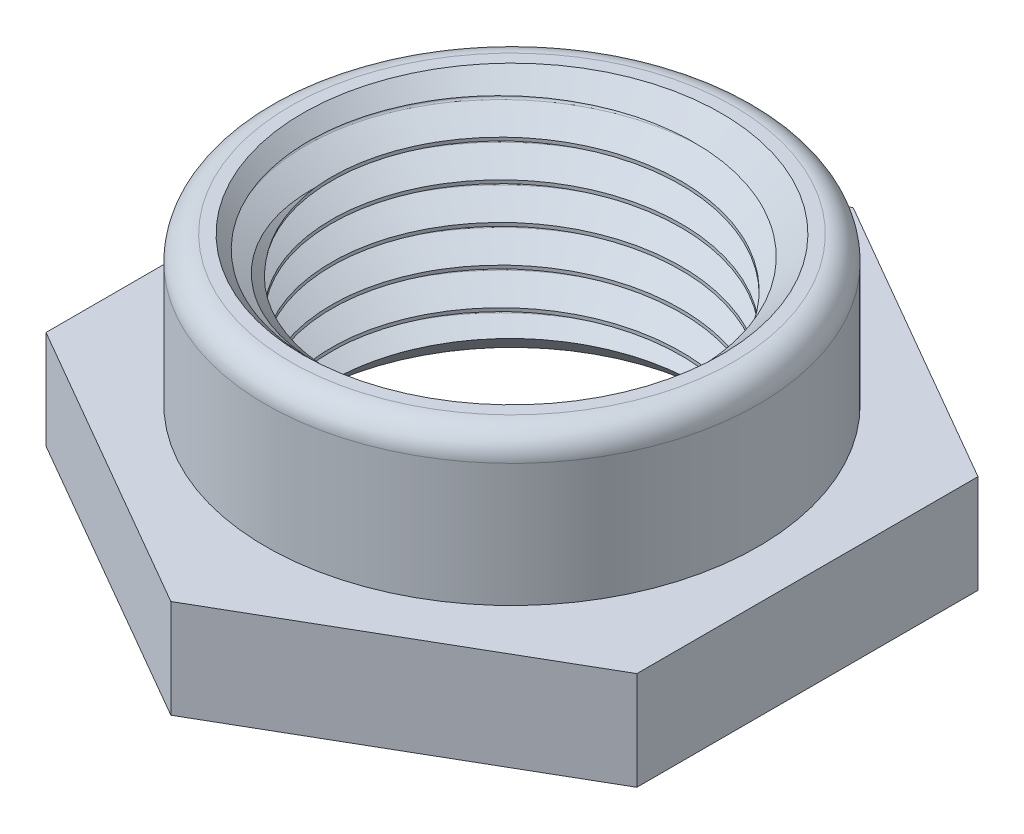
from build123d import *

# Parameters (mm, degrees)
CHAMFER_1_SIZE      = 0.7
SWEEP_9_PITCH       = 0.7500000000000011
SWEEP_9_HEIGHT      = 6.000000000000004
SWEEP_9_RADIUS      = 3.5
SWEEP_9_START_ANGLE = 89.99999999999982
SKETCH_6_R          = 7.5
CUT_EXTRUDE_1_DEPTH = 10


with BuildPart() as part:
    # Эскиз1 → Повернуть1 (revolve)
    with BuildSketch(Plane.XY, mode=Mode.PRIVATE) as revolve_1_sk:
        with BuildLine():
            Line((3.55, 0), (3.55, 5))
            Line((3.55, 5), (4.4999999999999964, 5))
            ThreePointArc((4.4999999999999964, 5), (4.853553390593274, 4.853553390593274), (5, 4.4999999999999964))
            Line((5, 4.4999999999999964), (5, 2))
            Line((5, 2), (6.999999999999999, 2))
            Line((6.999999999999999, 2), (7, 7e-17))
            Line((7, 7e-17), (3.55, 0))
        make_face()
    revolve(revolve_1_sk.sketch.rotate(Axis((0, 0, 0), (0, 1, 0)), 90), axis=Axis((0, 0, 0), (0, 1, 0)))

    # Фаска1
    chamfer_1_edges = [part.edges().sort_by_distance(p)[0] for p in [
        (-8.3e-16, 5, 3.55),
        (-8.3e-16, 0, 3.55),
    ]]
    chamfer(chamfer_1_edges, length=CHAMFER_1_SIZE)

    # Вырез-По траектории9: sweep along a helix
    with BuildLine() as sweep_9_path:
        add(Helix(SWEEP_9_PITCH, SWEEP_9_HEIGHT, SWEEP_9_RADIUS, center=(0, 5, 0), direction=(0, -1, 0), mode=Mode.PRIVATE).rotate(Axis((0, 5, 0), (0, -1, 0)), SWEEP_9_START_ANGLE))
    with BuildLine() as sweep_9_axis:
        Line((0, 5, 0), (0, -1.0000000000000044, 0))
    # Эскиз4 → Вырез-По траектории9 (sweep, cut)
    with BuildSketch(Plane.XY):
        with BuildLine():
            Line((3.5, 5.370000000000001), (3.5, 4.630000000000002))
            Line((3.5, 4.630000000000002), (4.06585879880049, 4.956698729810778))
            ThreePointArc((4.06585879880049, 4.956698729810778), (4.0908587988004905, 5.000000000000001), (4.06585879880049, 5.0433012701892235))
            Line((4.06585879880049, 5.0433012701892235), (3.5, 5.370000000000001))
        make_face()
    sweep(path=sweep_9_path.line, binormal=sweep_9_axis.edges()[0], mode=Mode.SUBTRACT)

    # Эскиз6 → Вырез-Вытянуть1 (cut)
    with BuildSketch(Plane.XZ):
        Circle(SKETCH_6_R)
        Polygon((2.6e-15, 6.928203230275513), (-6.0000000000000036, 3.4641016151377557), (-6.0000000000000036, -3.464101615137755), (-1.08e-15, -6.928203230275513), (6.000000000000003, -3.4641016151377553), (6.000000000000003, 3.4641016151377575), align=None, mode=Mode.SUBTRACT)
    extrude(amount=-CUT_EXTRUDE_1_DEPTH, mode=Mode.SUBTRACT)


solid = part.part
